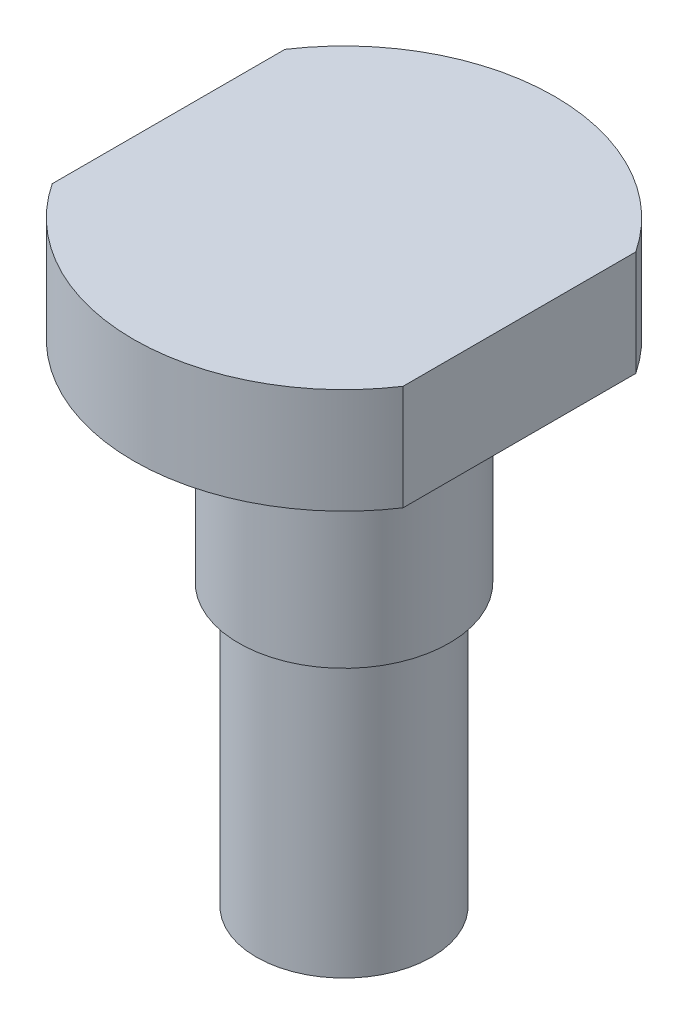
from build123d import *

# Parameters (mm, degrees)
SKETCH_2_W          = 2
SKETCH_2_H          = 8
CUT_EXTRUDE_1_DEPTH = 10


with BuildPart() as part:
    # 草图1 → 旋转1 (revolve)
    with BuildSketch(Plane(origin=(0, 0, 0), x_dir=(0, 0, -1), z_dir=(1, 0, 0))):
        Polygon((0, 0), (2.5, 0), (2.5, 8), (3, 8), (3, 14), (6, 14), (6, 17), (0, 17), align=None)
    revolve(axis=Axis((0, 0, 0), (0, 1, 0)))

    # 草图2 → 切除-拉伸1 (cut)
    with BuildSketch(Plane(origin=(0, 17, 0), x_dir=(1, 0, 0), z_dir=(0, 1, 0))):
        with Locations((-6, 0)):
            Rectangle(SKETCH_2_W, SKETCH_2_H)
        with Locations((6, 0)):
            Rectangle(SKETCH_2_W, SKETCH_2_H)
    extrude(amount=-CUT_EXTRUDE_1_DEPTH, mode=Mode.SUBTRACT)


solid = part.part
